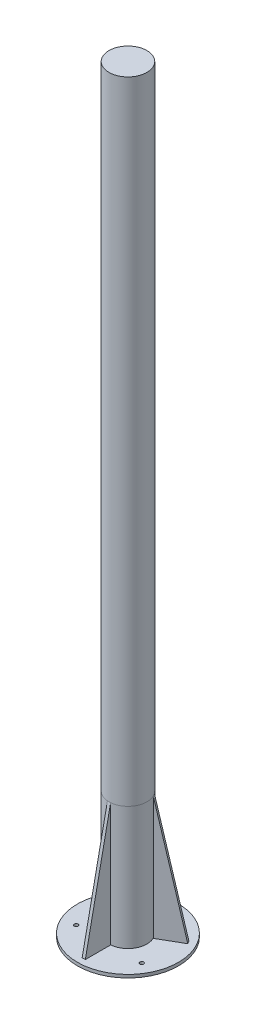
from build123d import *

# Parameters (mm, degrees)
SKETCH1_R                = 80
BOSS_EXTRUDE1_DEPTH      = 5
SKETCH2_R                = 30
BOSS_EXTRUDE2_DEPTH      = 195
BOSS_EXTRUDE3_DEPTH      = 2.5
BOSS_EXTRUDE3_DEPTH_BACK = 2.5
CIRPATTERN5_COUNT        = 3
SKETCH4_R                = 3
CUT_EXTRUDE1_DEPTH       = 226.444006352
SKETCH5_R                = 30
BOSS_EXTRUDE4_DEPTH      = 1000


with BuildPart() as part:
    # Sketch1 → Boss-Extrude1 (new body)
    with BuildSketch(Plane(origin=(0, 0, 0), x_dir=(1, 0, 0), z_dir=(0, 1, 0))):
        Circle(SKETCH1_R)
    extrude(amount=-BOSS_EXTRUDE1_DEPTH)

    # Sketch2 → Boss-Extrude2 (add)
    with BuildSketch(Plane(origin=(0, 0, 0), x_dir=(1, 0, 0), z_dir=(0, 1, 0))):
        Circle(SKETCH2_R)
    extrude(amount=BOSS_EXTRUDE2_DEPTH)

    # Sketch4 → Cut-Extrude1 (cut, through all)
    with BuildSketch(Plane(origin=(0, 0, 0), x_dir=(1, 0, 0), z_dir=(0, 1, 0))):
        with Locations((0, 60)):
            Circle(SKETCH4_R)
        with Locations((51.961524227, -30)):
            Circle(SKETCH4_R)
        with Locations((-51.961524227, -30)):
            Circle(SKETCH4_R)
    extrude(amount=-CUT_EXTRUDE1_DEPTH, mode=Mode.SUBTRACT)


with BuildPart() as body_2:
    # Sketch3 → Boss-Extrude3 (new, two sides: drawn at the far end of the back side and taken through both)
    with BuildSketch(Plane(origin=(0, 0, 0), x_dir=(0, 0, -1), z_dir=(1, 0, 0)).offset(-BOSS_EXTRUDE3_DEPTH_BACK)):
        Polygon((-70, 0), (-30, 0), (-30, 195), align=None)
    extrude(amount=BOSS_EXTRUDE3_DEPTH + BOSS_EXTRUDE3_DEPTH_BACK)


with BuildPart() as cirpattern5_1:
    # CirPattern5: pattern copy
    add(body_2.part.rotate(Axis((0, 195, 0), (0, -1, 0)), 1 * 360 / CIRPATTERN5_COUNT))


with BuildPart() as cirpattern5_2:
    # CirPattern5: pattern copy
    add(body_2.part.rotate(Axis((0, 195, 0), (0, -1, 0)), 2 * 360 / CIRPATTERN5_COUNT))


with BuildPart() as body_5:
    # Sketch5 → Boss-Extrude4 (new body)
    with BuildSketch(Plane(origin=(0, 195, 0), x_dir=(1, 0, 0), z_dir=(0, 1, 0))):
        Circle(SKETCH5_R)
    extrude(amount=BOSS_EXTRUDE4_DEPTH)


solid = Compound([part.part, body_2.part, cirpattern5_1.part, cirpattern5_2.part, body_5.part])
